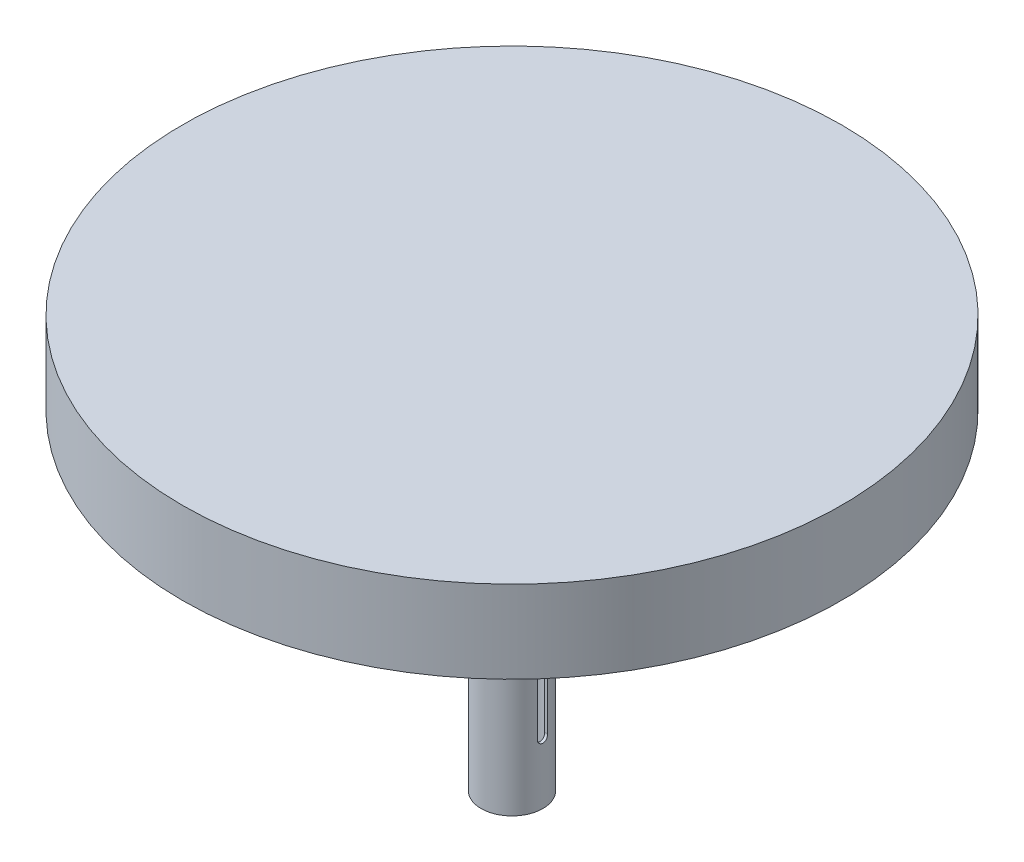
from build123d import *

# Parameters (mm, degrees)
SKETCH1_R               = 101.6
BOSS_EXTRUDE1_DEPTH     = 25.4
SKETCH2_R               = 9.525
SKETCH2_R_2             = 8.636
BOSS_EXTRUDE2_DEPTH     = 101.6
SKETCH3_R               = 2.38125
CUT_EXTRUDE1_DEPTH      = 102.6
CUT_EXTRUDE1_DEPTH_BACK = 102.6
CUT_EXTRUDE2_DEPTH      = 25.908
CUT_EXTRUDE2_DEPTH_BACK = 25.4


with BuildPart() as part:
    # Sketch1 → Boss-Extrude1 (new body)
    with BuildSketch(Plane(origin=(0, 0, 0), x_dir=(1, 0, 0), z_dir=(0, 1, 0))):
        Circle(SKETCH1_R)
    extrude(amount=BOSS_EXTRUDE1_DEPTH)

    # Sketch2 → Boss-Extrude2 (add)
    with BuildSketch(Plane.XZ):
        Circle(SKETCH2_R)
        Circle(SKETCH2_R_2, mode=Mode.SUBTRACT)
    extrude(amount=BOSS_EXTRUDE2_DEPTH)

    # Sketch3 → Cut-Extrude1 (cut, two sides)
    with BuildSketch(Plane.XY) as cut_extrude1_sk:
        with Locations((0, -12.7)):
            Circle(SKETCH3_R)
    extrude(amount=CUT_EXTRUDE1_DEPTH, mode=Mode.SUBTRACT)
    extrude(cut_extrude1_sk.sketch, amount=-CUT_EXTRUDE1_DEPTH_BACK, mode=Mode.SUBTRACT)

    # Sketch4 → Cut-Extrude2 (cut, two sides)
    with BuildSketch(Plane(origin=(0, 0, 0), x_dir=(0, 0, -1), z_dir=(1, 0, 0))) as cut_extrude2_sk:
        with BuildLine():
            Line((-1.5875, -82.55), (-1.5875, -57.15))
            ThreePointArc((-1.5875, -57.15), (0, -55.5625), (1.5875, -57.15))
            Line((1.5875, -57.15), (1.5875, -82.55))
            ThreePointArc((1.5875, -82.55), (0, -84.1375), (-1.5875, -82.55))
        make_face()
    extrude(amount=CUT_EXTRUDE2_DEPTH, mode=Mode.SUBTRACT)
    extrude(cut_extrude2_sk.sketch, amount=-CUT_EXTRUDE2_DEPTH_BACK, mode=Mode.SUBTRACT)


solid = part.part
